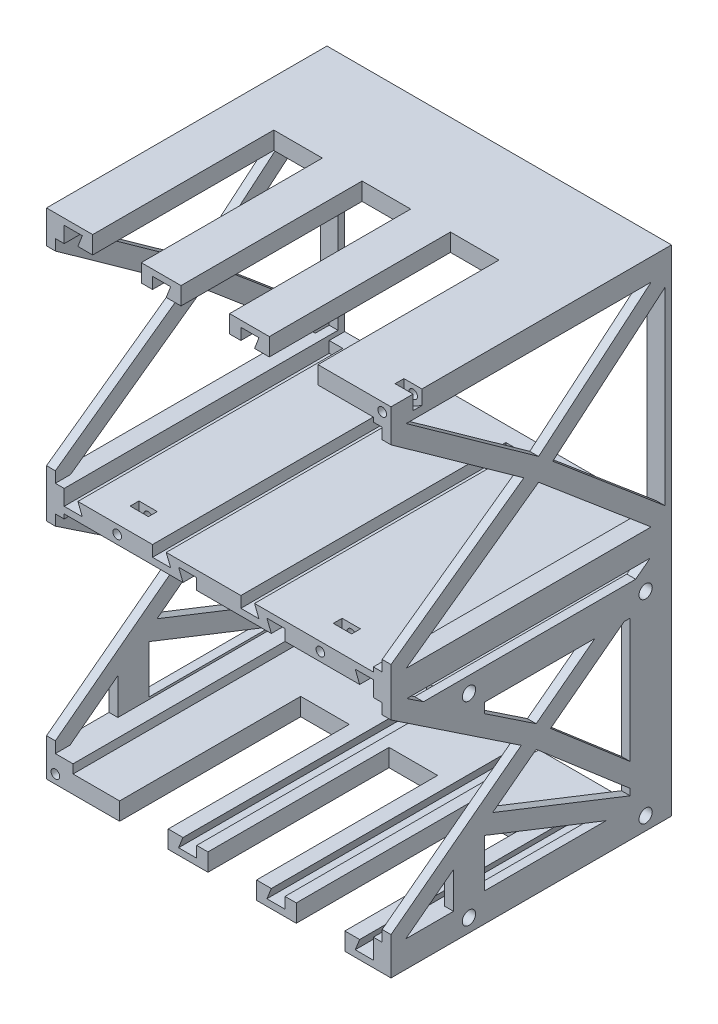
from build123d import *

# Parameters (mm, degrees)
BOUNDS_W                = 78
BOUNDS_H                = 112
BOUNDS_W_2              = 70
BOUNDS_H_2              = 104
BOSS_EXTRUDE3_DEPTH     = 63.5
SKETCH10_W              = 70
SKETCH10_H              = 4
BOSS_EXTRUDE4_DEPTH     = 63.5
CUT_EXTRUDE2_DEPTH      = 60
SKETCH13_W              = 74
SKETCH13_H              = 48
SKETCH13_H_2            = 47
CUT_EXTRUDE3_DEPTH      = 63
CUT_EXTRUDE4_DEPTH      = 40
CUT_EXTRUDE4_DEPTH_BACK = 40
SKETCH15_W              = 11
SKETCH15_H              = 4
CUT_EXTRUDE5_DEPTH      = 41
SKETCH15_4_W            = 11
SKETCH15_4_H            = 4
CUT_EXTRUDE6_DEPTH      = 41
LPATTERN1_COUNT         = 3
LPATTERN1_PITCH         = 20
LPATTERN2_COUNT         = 3
LPATTERN2_PITCH         = 20
BOSS_EXTRUDE5_DEPTH     = 2
BOSS_EXTRUDE6_DEPTH     = 2
BOSS_EXTRUDE7_DEPTH     = 2
SKETCH24_W              = 2
SKETCH24_H              = 6
BOSS_EXTRUDE9_DEPTH     = 50
SKETCH19_R              = 1.5
CUT_EXTRUDE7_DEPTH      = 4
SKETCH25_W              = 2
SKETCH25_H              = 2
BOSS_EXTRUDE10_DEPTH    = 63.5
SKETCH20_R              = 0.975
CUT_EXTRUDE8_DEPTH      = 10
CUT_EXTRUDE9_DEPTH      = 2
SKETCH26_W              = 68
SKETCH26_H              = 4
CUT_EXTRUDE10_DEPTH     = 6


with BuildPart() as part:
    # Bounds → Boss-Extrude3 (new body)
    with BuildSketch(Plane.XY):
        Rectangle(BOUNDS_W, BOUNDS_H)
        Rectangle(BOUNDS_W_2, BOUNDS_H_2, mode=Mode.SUBTRACT)
    extrude(amount=BOSS_EXTRUDE3_DEPTH)

    # Sketch10 → Boss-Extrude4 (add)
    with BuildSketch(Plane.XY):
        Rectangle(SKETCH10_W, SKETCH10_H)
    extrude(amount=BOSS_EXTRUDE4_DEPTH)

    # Sketch12 → Cut-Extrude2 (cut)
    with BuildSketch(Plane.XY.offset(63.5)):
        Polygon((-35, 52), (-35, 54.6), (-30.9, 54.6), (-31.9, 52), align=None)
        Polygon((-35, 2), (-35, -0.51), (-30.9, -0.51), (-31.9, 2), align=None)
        Polygon((35, -2), (35, 0.51), (30.9, 0.51), (31.9, -2), align=None)
        Polygon((35, -52), (31.9, -52), (30.9, -54.51), (35, -54.51), align=None)
        Polygon((-15, 52), (-15, 54.6), (-10.9, 54.6), (-11.9, 52), align=None)
        Polygon((-15, 2), (-15, -0.51), (-10.9, -0.51), (-11.9, 2), align=None)
        Polygon((5, 52), (5, 54.6), (9.1, 54.6), (8.1, 52), align=None)
        Polygon((5, 2), (5, -0.51), (9.1, -0.51), (8.1, 2), align=None)
        Polygon((15, -2), (15, 0.51), (10.9, 0.51), (11.9, -2), align=None)
        Polygon((15, -52), (11.9, -52), (10.9, -54.51), (15, -54.51), align=None)
        Polygon((-5, -2), (-5, 0.51), (-9.1, 0.51), (-8.1, -2), align=None)
        Polygon((-5, -52), (-8.1, -52), (-9.1, -54.51), (-5, -54.51), align=None)
    extrude(amount=-CUT_EXTRUDE2_DEPTH, mode=Mode.SUBTRACT)

    # Sketch13 → Cut-Extrude3 (cut, through all)
    with BuildSketch(Plane.XY.offset(1.5)):
        with Locations((0, 27)):
            Rectangle(SKETCH13_W, SKETCH13_H)
        with Locations((0, -26.5)):
            Rectangle(SKETCH13_W, SKETCH13_H_2)
    extrude(amount=CUT_EXTRUDE3_DEPTH, mode=Mode.SUBTRACT)

    # Sketch14 → Cut-Extrude4 (cut, two sides)
    with BuildSketch(Plane(origin=(0, 0, 0), x_dir=(0, 0, -1), z_dir=(1, 0, 0))) as cut_extrude4_sk:
        Polygon((-33.419183223, 27.032493094), (-63.5, 48.541321767), (-63.5, 5.461100044), align=None)
        Polygon((-30.083557049, 29.564761003), (-4.60655296, 51), (-60.061456201, 51), align=None)
        Polygon((-1.5, 5.616871887), (-1.5, 48.386281961), (-26.880029177, 27.03263342), align=None)
        Polygon((-60.068051987, 3), (-4.601280556, 3), (-30.08373711, 24.502190128), align=None)
        Polygon((-30.629837592, -22.572585649), (-4.810682054, -3), (-59.90183238, -3), align=None)
        Polygon((-1.5, -47.362849913), (-1.5, -5.509710589), (-27.375101601, -25.124706964), align=None)
        Polygon((-60.189317946, -50), (-4.568445355, -50), (-30.635861846, -27.596573602), align=None)
        Polygon((-34.002489964, -25.129273738), (-63.5, -5.405898349), (-63.5, -47.490289411), align=None)
    extrude(amount=CUT_EXTRUDE4_DEPTH, mode=Mode.SUBTRACT)
    extrude(cut_extrude4_sk.sketch, amount=-CUT_EXTRUDE4_DEPTH_BACK, mode=Mode.SUBTRACT)

    # Sketch15 → Cut-Extrude5 (cut)
    with BuildSketch(Plane.XY.offset(63.5)):
        with Locations((-23.05, 54)):
            Rectangle(SKETCH15_W, SKETCH15_H)
    cut_extrude5 = extrude(amount=-CUT_EXTRUDE5_DEPTH, mode=Mode.SUBTRACT)

    # Sketch15_4 → Cut-Extrude6 (cut)
    with BuildSketch(Plane.XY.offset(63.5)):
        with Locations((23.05, -54)):
            Rectangle(SKETCH15_4_W, SKETCH15_4_H)
    cut_extrude6 = extrude(amount=-CUT_EXTRUDE6_DEPTH, mode=Mode.SUBTRACT)

    # LPattern1: Cut-Extrude5 ×3
    with Locations(*[(i * LPATTERN1_PITCH, 0, 0) for i in range(1, LPATTERN1_COUNT)]):
        add(cut_extrude5, mode=Mode.SUBTRACT)

    # LPattern2: Cut-Extrude6 ×3
    with Locations(*[(-i * LPATTERN2_PITCH, 0, 0) for i in range(1, LPATTERN2_COUNT)]):
        add(cut_extrude6, mode=Mode.SUBTRACT)

    # Sketch17 → Boss-Extrude5 (add)
    with BuildSketch(Plane(origin=(39, 0, 0), x_dir=(0, 0, -1), z_dir=(1, 0, 0))):
        Polygon((-8.108554395, -5.5), (-49.35, -5.5), (-49.35, -10.055434538), (-42.35, -14.735952573), (-42.35, -12.5), (-17.342596948, -12.5), align=None)
        Polygon((-2.35, -46.632324415), (-2.35, -6.154065428), (-10.72123284, -12.5), (-9.35, -12.5), (-9.35, -40.61623207), align=None)
        Polygon((-42.35, -36.476646073), (-49.35, -41.783097686), (-49.35, -50), (-4.568445355, -50), (-9.35, -45.890532244), (-9.35, -49.5), (-42.35, -49.5), align=None)
    boss_extrude5 = extrude(amount=-BOSS_EXTRUDE5_DEPTH)

    # Sketch18 → Boss-Extrude6 (add)
    with BuildSketch(Plane(origin=(39, 0, 0), x_dir=(0, 0, -1), z_dir=(1, 0, 0))):
        Polygon((-1.5, -47.362849913), (-1.5, -5.509710589), (-2.392318385, -6.186145494), (-2.35, -46.632324415), align=None)
    boss_extrude6 = extrude(amount=-BOSS_EXTRUDE6_DEPTH)

    # Sketch22 → Boss-Extrude7 (add)
    with BuildSketch(Plane(origin=(39, 0, 0), x_dir=(0, 0, -1), z_dir=(1, 0, 0))):
        Polygon((-40.484734787, -35.062654702), (-42.35, -36.476646073), (-9.35, -49.5), (-9.35, -47.349887143), align=None)
        Polygon((-9.35, -49.5), (-42.35, -36.476646073), (-42.35, -38.62675893), (-14.798191356, -49.5), align=None)
        Polygon((-49.35, -10.055434538), (-49.35, -5.5), (-56.162930005, -5.5), align=None)
    boss_extrude7 = extrude(amount=-BOSS_EXTRUDE7_DEPTH)

    # Sketch24 → Boss-Extrude9 (add)
    with BuildSketch(Plane.XY.offset(1.5)):
        with Locations((36, -9)):
            Rectangle(SKETCH24_W, SKETCH24_H)
    boss_extrude9 = extrude(amount=BOSS_EXTRUDE9_DEPTH)

    # Sketch19 → Cut-Extrude7 (cut)
    with BuildSketch(Plane(origin=(39, 0, 0), x_dir=(0, 0, -1), z_dir=(1, 0, 0))):
        with Locations((-5.85, -9)):
            Circle(SKETCH19_R)
        with Locations((-45.85, -9)):
            Circle(SKETCH19_R)
        with Locations((-5.85, -53)):
            Circle(SKETCH19_R)
        with Locations((-45.85, -53)):
            Circle(SKETCH19_R)
    cut_extrude7 = extrude(amount=-CUT_EXTRUDE7_DEPTH, mode=Mode.SUBTRACT)

    # Mirror2: Boss-Extrude5, Boss-Extrude6, Boss-Extrude7, Boss-Extrude9, Cut-Extrude7 across plane
    add(boss_extrude5.mirror(Plane(origin=(0, 0, 0), x_dir=(0, 0, 1), z_dir=(1, 0, 0))))
    add(boss_extrude6.mirror(Plane(origin=(0, 0, 0), x_dir=(0, 0, 1), z_dir=(1, 0, 0))))
    add(boss_extrude7.mirror(Plane(origin=(0, 0, 0), x_dir=(0, 0, 1), z_dir=(1, 0, 0))))
    add(boss_extrude9.mirror(Plane(origin=(0, 0, 0), x_dir=(0, 0, 1), z_dir=(1, 0, 0))))
    add(cut_extrude7.mirror(Plane(origin=(0, 0, 0), x_dir=(0, 0, 1), z_dir=(1, 0, 0))), mode=Mode.SUBTRACT)

    # Sketch25 → Boss-Extrude10 (add)
    with BuildSketch(Plane.XY.offset(63.5)):
        with Locations((-34, -51)):
            Rectangle(SKETCH25_W, SKETCH25_H)
    extrude(amount=-BOSS_EXTRUDE10_DEPTH)

    # Sketch20 → Cut-Extrude8 (cut)
    with BuildSketch(Plane.XY.offset(63.5)):
        with Locations((37, 54)):
            Circle(SKETCH20_R)
        with Locations((-37, -54)):
            Circle(SKETCH20_R)
        with Locations((-23, 0)):
            Circle(SKETCH20_R)
        with Locations((23, 0)):
            Circle(SKETCH20_R)
    extrude(amount=-CUT_EXTRUDE8_DEPTH, mode=Mode.SUBTRACT)

    # Sketch21 → Cut-Extrude9 (cut)
    with BuildSketch(Plane.XY.offset(58.5)):
        Polygon((39.075, 52.801998191), (39.075, 55.198001809), (37, 56.396003617), (34.925, 55.198001809), (34.925, 52.801998191), (37, 51.603996383), align=None)
        Polygon((39.075, 56.396003617), (37, 56.396003617), (39.075, 55.198001809), align=None)
        Polygon((34.925, 55.198001809), (37, 56.396003617), (34.925, 56.396003617), align=None)
        Polygon((-20.925, -1.198001809), (-20.925, 1.198001809), (-23, 2.396003617), (-25.075, 1.198001809), (-25.075, -1.198001809), (-23, -2.396003617), align=None)
        Polygon((-20.925, 2.396003617), (-23, 2.396003617), (-20.925, 1.198001809), align=None)
        Polygon((-25.075, 1.198001809), (-23, 2.396003617), (-25.075, 2.396003617), align=None)
        Polygon((25.075, -1.198001809), (25.075, 1.198001809), (23, 2.396003617), (20.925, 1.198001809), (20.925, -1.198001809), (23, -2.396003617), align=None)
        Polygon((20.925, 1.198001809), (23, 2.396003617), (20.925, 2.396003617), align=None)
        Polygon((25.075, 2.396003617), (23, 2.396003617), (25.075, 1.198001809), align=None)
        Polygon((-34.925, -55.198001809), (-34.925, -52.801998191), (-37, -51.603996383), (-39.075, -52.801998191), (-39.075, -55.198001809), (-37, -56.396003617), align=None)
        Polygon((-37, -56.396003617), (-39.075, -55.198001809), (-39.075, -56.396003617), align=None)
        Polygon((-34.925, -56.396003617), (-34.925, -55.198001809), (-37, -56.396003617), align=None)
    extrude(amount=-CUT_EXTRUDE9_DEPTH, mode=Mode.SUBTRACT)

    # Sketch26 → Cut-Extrude10 (cut)
    with BuildSketch(Plane(origin=(0, 0, 0), x_dir=(-1, 0, 0), z_dir=(0, 0, -1))):
        with Locations((-1, -54)):
            Rectangle(SKETCH26_W, SKETCH26_H)
    extrude(amount=-CUT_EXTRUDE10_DEPTH, mode=Mode.SUBTRACT)


solid = part.part
